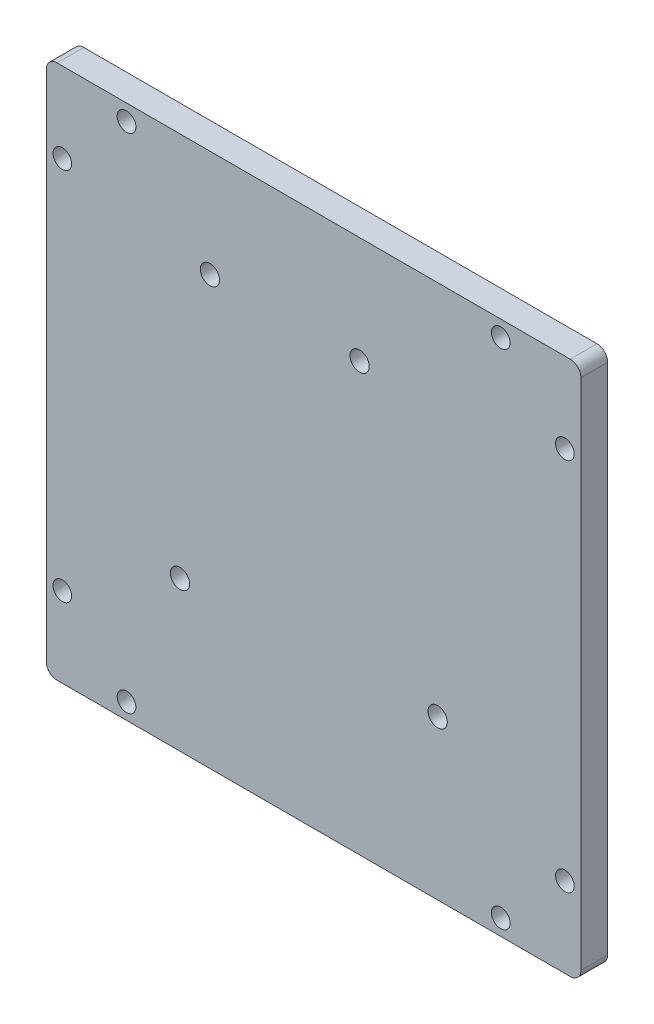
from build123d import *

# Parameters (mm, degrees)
SKETCH_1_R      = 1.75
SKETCH_1_R_2    = 1.8
EXTRUDE_1_DEPTH = 5


with BuildPart() as part:
    # Эскиз1 → Бобышка-Вытянуть1 (new body)
    with BuildSketch(Plane.XY):
        with BuildLine():
            Line((-48, -50), (48, -50))
            ThreePointArc((48, -50), (49.414213562, -49.414213562), (50, -48))
            Line((50, -48), (50, 48))
            ThreePointArc((50, 48), (49.414213562, 49.414213562), (48, 50))
            Line((48, 50), (-48, 50))
            ThreePointArc((-48, 50), (-49.414213562, 49.414213562), (-50, 48))
            Line((-50, 48), (-50, -48))
            ThreePointArc((-50, -48), (-49.414213562, -49.414213562), (-48, -50))
        make_face()
        with Locations((-47, 35)):
            Circle(SKETCH_1_R, mode=Mode.SUBTRACT)
        with Locations((47, 35)):
            Circle(SKETCH_1_R, mode=Mode.SUBTRACT)
        with Locations((47, -35)):
            Circle(SKETCH_1_R, mode=Mode.SUBTRACT)
        with Locations((-47, -35)):
            Circle(SKETCH_1_R, mode=Mode.SUBTRACT)
        with Locations((-35, 47)):
            Circle(SKETCH_1_R, mode=Mode.SUBTRACT)
        with Locations((35, 47)):
            Circle(SKETCH_1_R, mode=Mode.SUBTRACT)
        with Locations((-35, -47)):
            Circle(SKETCH_1_R, mode=Mode.SUBTRACT)
        with Locations((35, -47)):
            Circle(SKETCH_1_R, mode=Mode.SUBTRACT)
        with Locations((-19.4, 30)):
            Circle(SKETCH_1_R_2, mode=Mode.SUBTRACT)
        with Locations((8.6, 30)):
            Circle(SKETCH_1_R_2, mode=Mode.SUBTRACT)
        with Locations((-25, -22)):
            Circle(SKETCH_1_R_2, mode=Mode.SUBTRACT)
        with Locations((23.2, -20.3)):
            Circle(SKETCH_1_R_2, mode=Mode.SUBTRACT)
    extrude(amount=EXTRUDE_1_DEPTH)


solid = part.part
